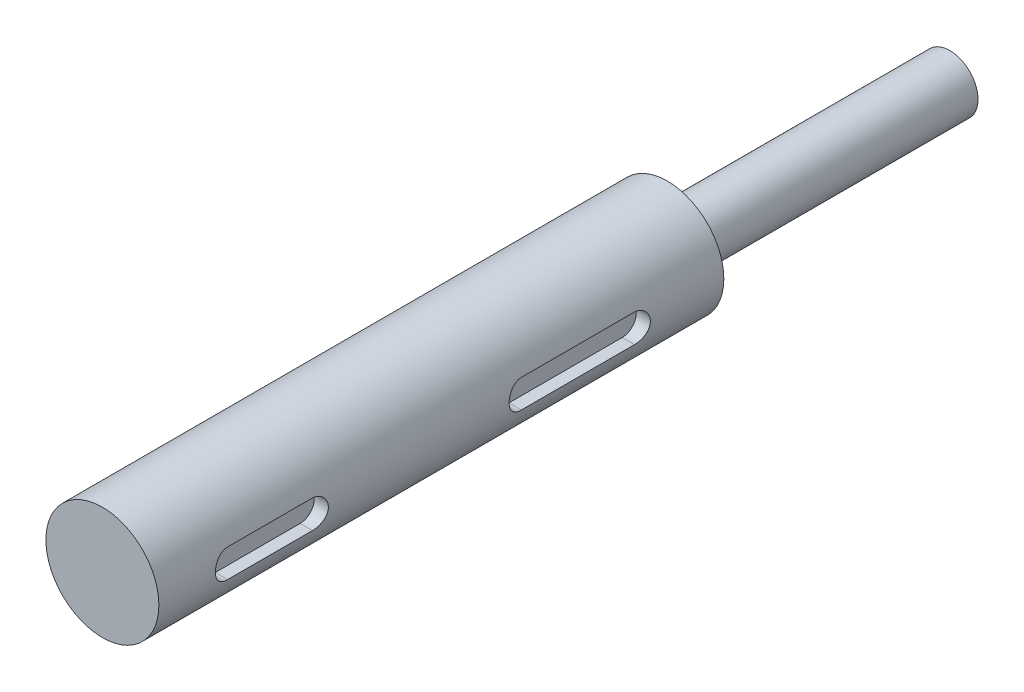
from build123d import *

# Parameters (mm, degrees)
SKETCH_1_R          = 4
EXTRUDE_1_DEPTH     = 40
SKETCH_2_R          = 2
EXTRUDE_2_DEPTH     = 20
CUT_EXTRUDE_1_DEPTH = 2


with BuildPart() as part:
    # ｽｹｯﾁ1 → ﾎﾞｽ - 押し出し1 (new body)
    with BuildSketch(Plane.XY):
        Circle(SKETCH_1_R)
    extrude(amount=EXTRUDE_1_DEPTH)

    # ｽｹｯﾁ2 → ﾎﾞｽ - 押し出し2 (add)
    with BuildSketch(Plane(origin=(0, 0, 0), x_dir=(-1, 0, 0), z_dir=(0, 0, -1))):
        Circle(SKETCH_2_R)
    extrude(amount=EXTRUDE_2_DEPTH)

    # ｽｹｯﾁ3 → ｶｯﾄ - 押し出し1 (cut, through all)
    with BuildSketch(Plane(origin=(3, 0, 0), x_dir=(0, 0, -1), z_dir=(1, 0, 0))):
        with BuildLine():
            Line((-35, 1), (-29, 1))
            ThreePointArc((-29, 1), (-28, 0), (-29, -1))
            Line((-29, -1), (-35, -1))
            ThreePointArc((-35, -1), (-36, 0), (-35, 1))
        make_face()
        with BuildLine():
            Line((-14.2, 1), (-6.2, 1))
            ThreePointArc((-6.2, 1), (-5.2, 0), (-6.2, -1))
            Line((-6.2, -1), (-14.2, -1))
            ThreePointArc((-14.2, -1), (-15.2, 0), (-14.2, 1))
        make_face()
    extrude(amount=CUT_EXTRUDE_1_DEPTH, mode=Mode.SUBTRACT)


solid = part.part
